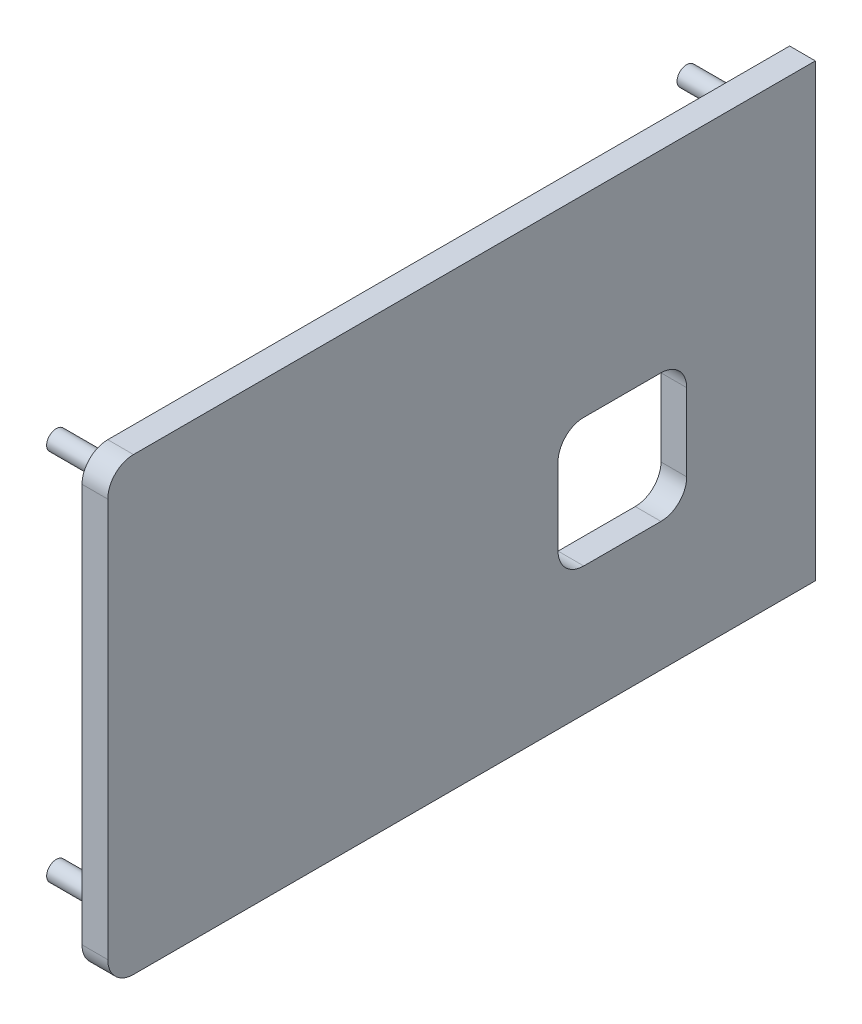
from build123d import *

# Parameters (mm, degrees)
SKETCH2_W           = 139.7
SKETCH2_H           = 88.9
BOSS_EXTRUDE1_DEPTH = 5.08
SKETCH3_R           = 1.905
BOSS_EXTRUDE2_DEPTH = 12.7
FILLET1_R           = 5.08
SKETCH4_W           = 25.4
SKETCH4_H           = 25.4
CUT_EXTRUDE1_DEPTH  = 5.08
FILLET2_R           = 5.08


with BuildPart() as part:
    # Sketch2 → Boss-Extrude1 (new body)
    with BuildSketch(Plane(origin=(0, 0, 0), x_dir=(0, 0, -1), z_dir=(1, 0, 0))):
        with Locations((0.114290462, 4.230322371)):
            Rectangle(SKETCH2_W, SKETCH2_H)
    extrude(amount=BOSS_EXTRUDE1_DEPTH)

    # Sketch3 → Boss-Extrude2 (add)
    with BuildSketch(Plane.ZY):
        with Locations((-62.344290462, 41.060322371)):
            Circle(SKETCH3_R)
        with Locations((-62.344290462, -32.599677629)):
            Circle(SKETCH3_R)
        with Locations((62.115709538, 41.060322371)):
            Circle(SKETCH3_R)
        with Locations((62.115709538, -32.599677629)):
            Circle(SKETCH3_R)
    extrude(amount=BOSS_EXTRUDE2_DEPTH)

    # Fillet1
    fillet1_edges = [part.edges().sort_by_distance(p)[0] for p in [
        (2.54, -40.219677629, 69.735709538),
        (2.54, 48.680322371, 69.735709538),
    ]]
    fillet(fillet1_edges, radius=FILLET1_R)

    # Sketch4 → Cut-Extrude1 (cut)
    with BuildSketch(Plane(origin=(5.08, 0, 0), x_dir=(0, 0, -1), z_dir=(1, 0, 0))):
        with Locations((31.864290462, -2.119677629)):
            Rectangle(SKETCH4_W, SKETCH4_H)
    extrude(amount=-CUT_EXTRUDE1_DEPTH, mode=Mode.SUBTRACT)

    # Fillet2
    fillet2_edges = [part.edges().sort_by_distance(p)[0] for p in [
        (2.54, 10.580322371, -44.564290462),
        (2.54, -14.819677629, -44.564290462),
        (2.54, -14.819677629, -19.164290462),
        (2.54, 10.580322371, -19.164290462),
    ]]
    fillet(fillet2_edges, radius=FILLET2_R)


solid = part.part
